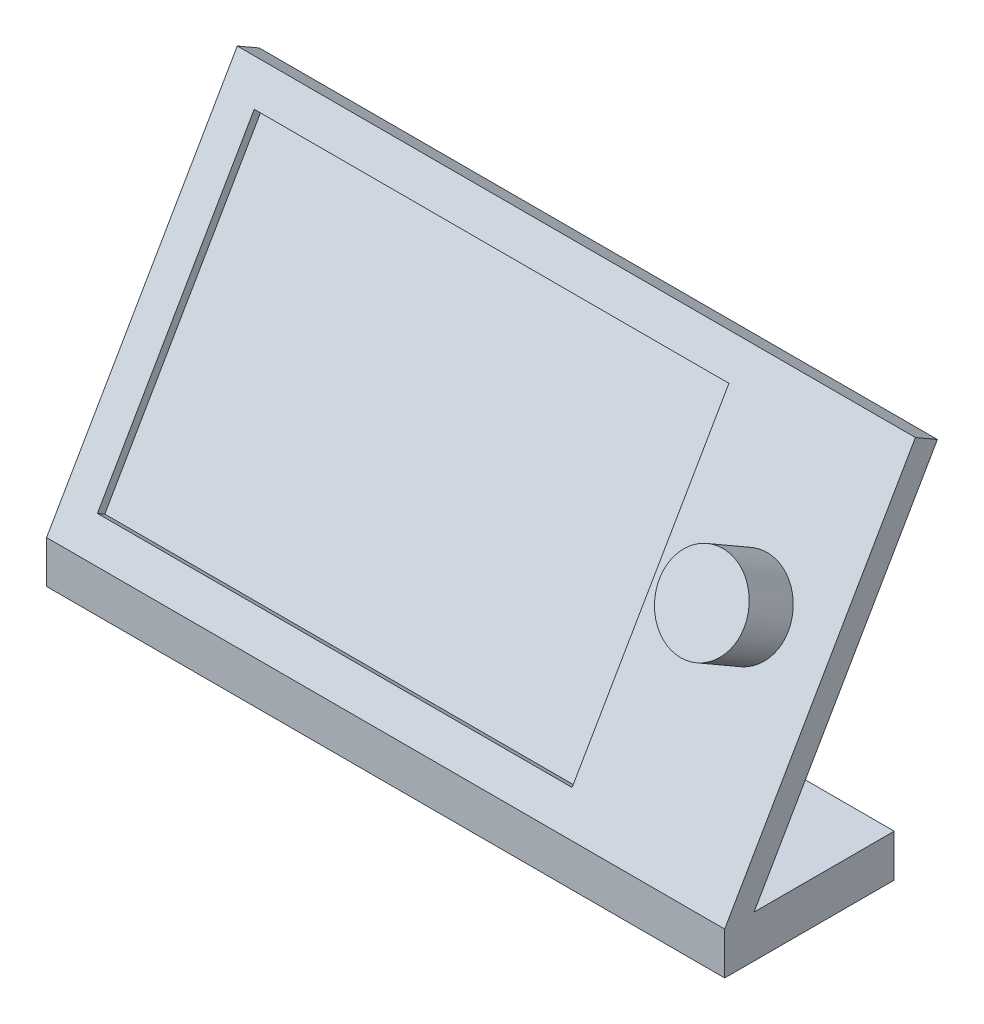
from build123d import *

# Parameters (mm, degrees)
SKETCH1_W           = 101.6
SKETCH1_H           = 6.35
BOSS_EXTRUDE1_DEPTH = 25.4
BOSS_EXTRUDE2_DEPTH = 101.6
SKETCH3_W           = 71.12
SKETCH3_H           = 46.99
CUT_EXTRUDE1_DEPTH  = 1.27
SKETCH4_R           = 6.35
BOSS_EXTRUDE3_DEPTH = 7.62


with BuildPart() as part:
    # Sketch1 → Boss-Extrude1 (new body)
    with BuildSketch(Plane.XY):
        with Locations((-50.8, 3.175)):
            Rectangle(SKETCH1_W, SKETCH1_H)
    extrude(amount=BOSS_EXTRUDE1_DEPTH)

    # Sketch2 → Boss-Extrude2 (add)
    with BuildSketch(Plane(origin=(0, 0, 0), x_dir=(0, 0, -1), z_dir=(1, 0, 0))):
        Polygon((-25.4, 6.35), (3.175, 55.843351826), (6.474556788, 53.938351826), (-21.000590949, 6.35), align=None)
    extrude(amount=-BOSS_EXTRUDE2_DEPTH)

    # Sketch3 → Cut-Extrude1 (cut)
    with BuildSketch(Plane(origin=(0, 12.586022628, 21.799630657), x_dir=(1, 0, 0), z_dir=(0, 0.5, 0.866025404))):
        with Locations((-60.96, 21.374261314)):
            Rectangle(SKETCH3_W, SKETCH3_H)
    extrude(amount=-CUT_EXTRUDE1_DEPTH, mode=Mode.SUBTRACT)

    # Sketch4 → Boss-Extrude3 (add)
    with BuildSketch(Plane(origin=(0, 12.586022628, 21.799630657), x_dir=(1, 0, 0), z_dir=(0, 0.5, 0.866025404))):
        with Locations((-12.7, 24.549261314)):
            Circle(SKETCH4_R)
    extrude(amount=BOSS_EXTRUDE3_DEPTH)


solid = part.part
